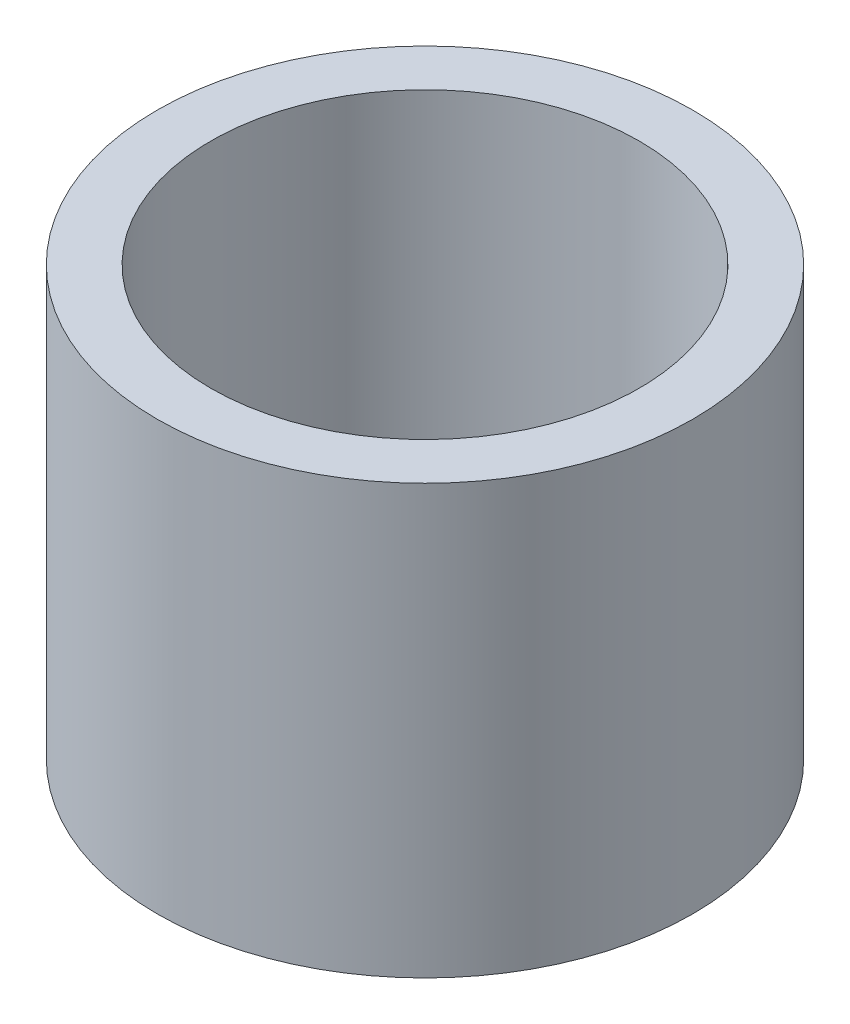
from build123d import *

# Parameters (mm, degrees)
SKETCH1_R           = 15.875
SKETCH1_R_2         = 12.7
BOSS_EXTRUDE1_DEPTH = 25.4


with BuildPart() as part:
    # Sketch1 → Boss-Extrude1 (new body)
    with BuildSketch(Plane(origin=(0, 0, 0), x_dir=(1, 0, 0), z_dir=(0, 1, 0))):
        Circle(SKETCH1_R)
        Circle(SKETCH1_R_2, mode=Mode.SUBTRACT)
    extrude(amount=BOSS_EXTRUDE1_DEPTH)


solid = part.part
